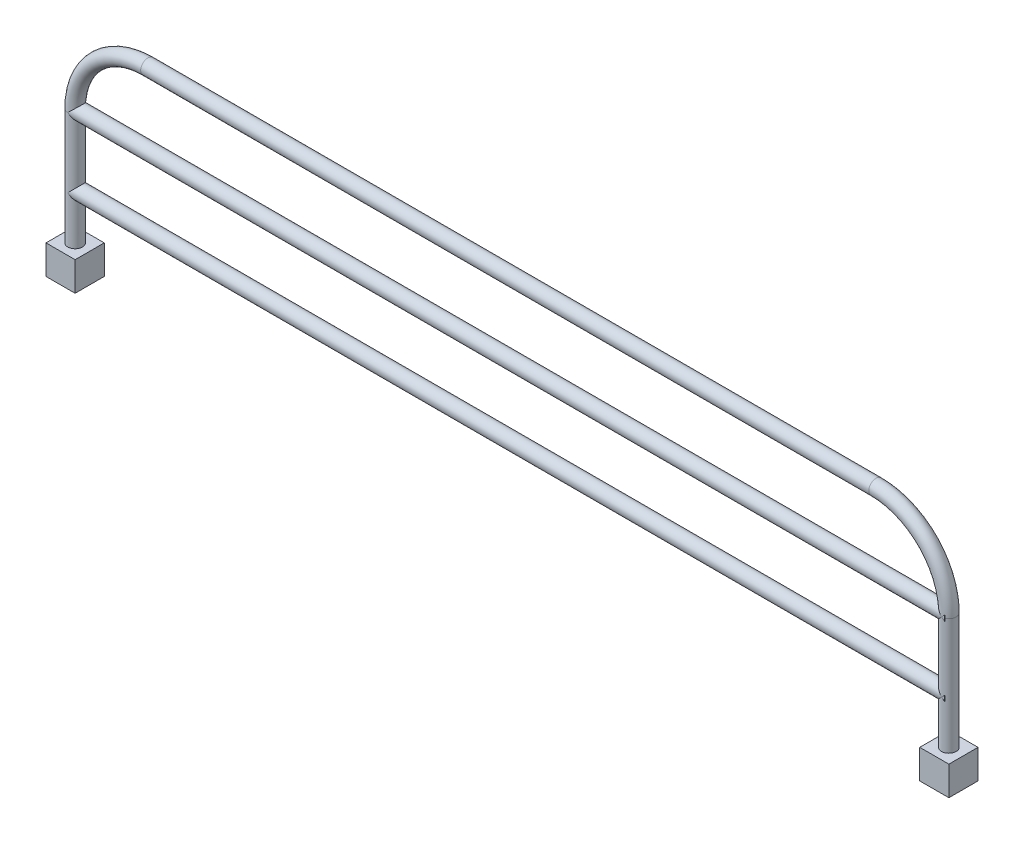
from build123d import *

# Parameters (mm, degrees)
SKETCH2_R           = 12.7
SKETCH3_W           = 50.8
SKETCH3_H           = 50.8
BOSS_EXTRUDE1_DEPTH = 50.8
SKETCH4_R           = 12.7
BOSS_EXTRUDE2_DEPTH = 1528.8
SKETCH5_R           = 12.7
BOSS_EXTRUDE3_DEPTH = 1528.8


with BuildPart() as part:
    # Sweep1: sweep along a path in Sketch1
    with BuildLine(Plane.XY) as sweep1_path:
        Line((0, 0), (0, 203.2))
        ThreePointArc((0, 203.2), (37.197438789, 293.002561211), (127, 330.2))
        Line((127, 330.2), (1397, 330.2))
        ThreePointArc((1397, 330.2), (1486.802561211, 293.002561211), (1524, 203.2))
        Line((1524, 203.2), (1524, 0))
    # Sketch2 → Sweep1 (sweep)
    with BuildSketch(Plane(origin=(0, 0, 0), x_dir=(1, 0, 0), z_dir=(0, 1, 0))):
        Circle(SKETCH2_R)
    sweep(path=sweep1_path.line)

    # Sketch3 → Boss-Extrude1 (add)
    with BuildSketch(Plane.XZ):
        Rectangle(SKETCH3_W, SKETCH3_H)
        with Locations((1524, 0)):
            Rectangle(SKETCH3_W, SKETCH3_H)
    extrude(amount=BOSS_EXTRUDE1_DEPTH)

    # Sketch4 → Boss-Extrude2 (add)
    with BuildSketch(Plane(origin=(0, 0, 0), x_dir=(0, 0, -1), z_dir=(1, 0, 0))):
        with Locations((0, 203.2)):
            Circle(SKETCH4_R)
    extrude(amount=BOSS_EXTRUDE2_DEPTH)

    # Sketch5 → Boss-Extrude3 (add)
    with BuildSketch(Plane(origin=(0, 0, 0), x_dir=(0, 0, -1), z_dir=(1, 0, 0))):
        with Locations((0, 82.09908093)):
            Circle(SKETCH5_R)
    extrude(amount=BOSS_EXTRUDE3_DEPTH)


solid = part.part
